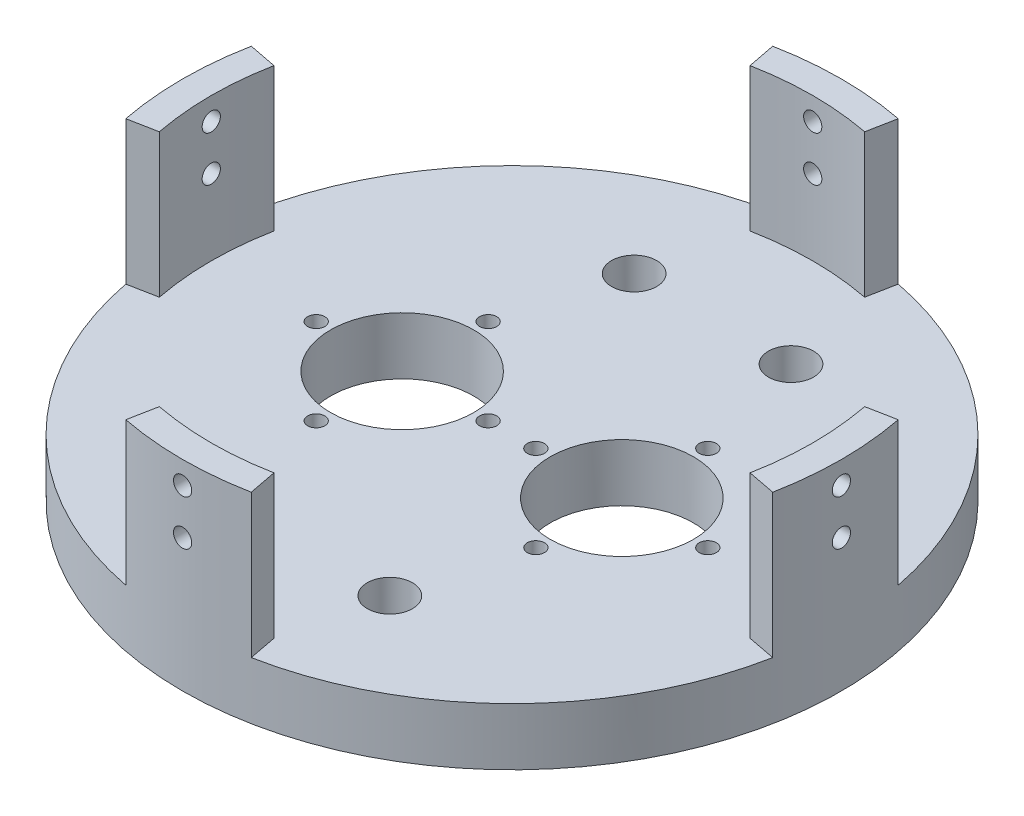
from build123d import *

# Parameters (mm, degrees)
SKETCH1_R                       = 73.025
BASE_EXTRUDE_DEPTH              = 12.7
STANDOFFS_DEPTH                 = 31.75
CIRPATTERN1_COUNT               = 4
F_10_32_TAPPED_HOLE1_AT_2_COUNT = 2
F_10_32_TAPPED_HOLE1_AT_2_PITCH = 10
CIRPATTERN2_COUNT               = 4
SKETCH3_R                       = 15.875
SKETCH3_R_2                     = 1.905
SKETCH3_R_3                     = 4.99999
BODY_HOLES_DEPTH                = 12.7


with BuildPart() as part:
    # Sketch1 → Base Extrude (new body)
    with BuildSketch(Plane(origin=(0, 0, 0), x_dir=(1, 0, 0), z_dir=(0, 1, 0))):
        Circle(SKETCH1_R)
    extrude(amount=BASE_EXTRUDE_DEPTH)

    # Sketch2 → Standoffs (add)
    with BuildSketch(Plane(origin=(0, 12.7, 0), x_dir=(1, 0, 0), z_dir=(0, 1, 0))):
        with BuildLine():
            ThreePointArc((-65.454301807, -12.7), (-66.675, 0), (-65.454301807, 12.7))
            Line((-65.454301807, 12.7), (-71.688044836, 13.90952381))
            ThreePointArc((-71.688044836, 13.90952381), (-73.025, 0), (-71.688044836, -13.90952381))
            Line((-71.688044836, -13.90952381), (-65.454301807, -12.7))
        make_face()
    standoffs = extrude(amount=STANDOFFS_DEPTH)

    # CirPattern1: Standoffs ×4 about axis
    cirpattern1_axis = Axis((0, 0, 0), (0, 1, 0))
    for i in range(1, CIRPATTERN1_COUNT):
        add(standoffs.rotate(cirpattern1_axis, i * 360 / CIRPATTERN1_COUNT))

    # Sketch7 → #10-32 Tapped Hole1 (revolve, cut)
    with BuildSketch(Plane(origin=(-73.025, 39.45, 0), x_dir=(0, 0, 1), z_dir=(0, 1, 0))):
        Polygon((0, 0), (0, 26.613317848), (2.0193, 25.4), (2.0193, 0), align=None)
    f_10_32_tapped_hole1 = revolve(axis=Axis((-79.375, 39.45, 0), (1, 0, 0)), mode=Mode.SUBTRACT)

    # #10-32 Tapped Hole1 at 2: #10-32 Tapped Hole1 ×2
    with Locations(*[(0, -i * F_10_32_TAPPED_HOLE1_AT_2_PITCH, 0) for i in range(1, F_10_32_TAPPED_HOLE1_AT_2_COUNT)]):
        add(f_10_32_tapped_hole1, mode=Mode.SUBTRACT)

    # CirPattern2: #10-32 Tapped Hole1 ×4 about axis
    cirpattern2_axis = Axis((0, 0, 0), (0, 1, 0))
    for i in range(1, CIRPATTERN2_COUNT):
        add(f_10_32_tapped_hole1.rotate(cirpattern2_axis, i * 360 / CIRPATTERN2_COUNT), mode=Mode.SUBTRACT)

    # CirPattern2 copy 1 sketch → CirPattern2 copy 1 (revolve, cut)
    with BuildSketch(Plane(origin=(0, 29.45, 73.025), x_dir=(1, 0, 0), z_dir=(0, 1, 0))):
        Polygon((0, 0), (0, 26.613317848), (2.0193, 25.4), (2.0193, 0), align=None)
    revolve(axis=Axis((0, 29.45, 79.375), (0, 0, -1)), mode=Mode.SUBTRACT)

    # CirPattern2 copy 2 sketch → CirPattern2 copy 2 (revolve, cut)
    with BuildSketch(Plane(origin=(73.025, 29.45, 0), x_dir=(0, 0, -1), z_dir=(0, 1, 0))):
        Polygon((0, 0), (0, 26.613317848), (2.0193, 25.4), (2.0193, 0), align=None)
    revolve(axis=Axis((79.375, 29.45, 0), (-1, 0, 0)), mode=Mode.SUBTRACT)

    # CirPattern2 copy 3 sketch → CirPattern2 copy 3 (revolve, cut)
    with BuildSketch(Plane(origin=(0, 29.45, -73.025), x_dir=(-1, 0, 0), z_dir=(0, 1, 0))):
        Polygon((0, 0), (0, 26.613317848), (2.0193, 25.4), (2.0193, 0), align=None)
    revolve(axis=Axis((0, 29.45, -79.375), (0, 0, 1)), mode=Mode.SUBTRACT)

    # Sketch3 → Body-Holes (cut)
    with BuildSketch(Plane(origin=(0, 12.7, 0), x_dir=(1, 0, 0), z_dir=(0, 1, 0))):
        with Locations((-24.34209, 0)):
            Circle(SKETCH3_R)
        with Locations((24.34209, 0)):
            Circle(SKETCH3_R)
        with Locations((-24.34209, 19.05)):
            Circle(SKETCH3_R_2)
        with Locations((-24.34209, -19.05)):
            Circle(SKETCH3_R_2)
        with Locations((-17.37995, -44.45)):
            Circle(SKETCH3_R_3)
        with Locations((17.37995, -44.45)):
            Circle(SKETCH3_R_3)
        with Locations((17.37995, 44.45)):
            Circle(SKETCH3_R_3)
        with Locations((-17.37995, 44.45)):
            Circle(SKETCH3_R_3)
        with Locations((-43.39209, 0)):
            Circle(SKETCH3_R_2)
        with Locations((-5.29209, 0)):
            Circle(SKETCH3_R_2)
        with Locations((24.34209, -19.05)):
            Circle(SKETCH3_R_2)
        with Locations((43.39209, 0)):
            Circle(SKETCH3_R_2)
        with Locations((5.29209, 0)):
            Circle(SKETCH3_R_2)
        with Locations((24.34209, 19.05)):
            Circle(SKETCH3_R_2)
    extrude(amount=-BODY_HOLES_DEPTH, mode=Mode.SUBTRACT)


solid = part.part
